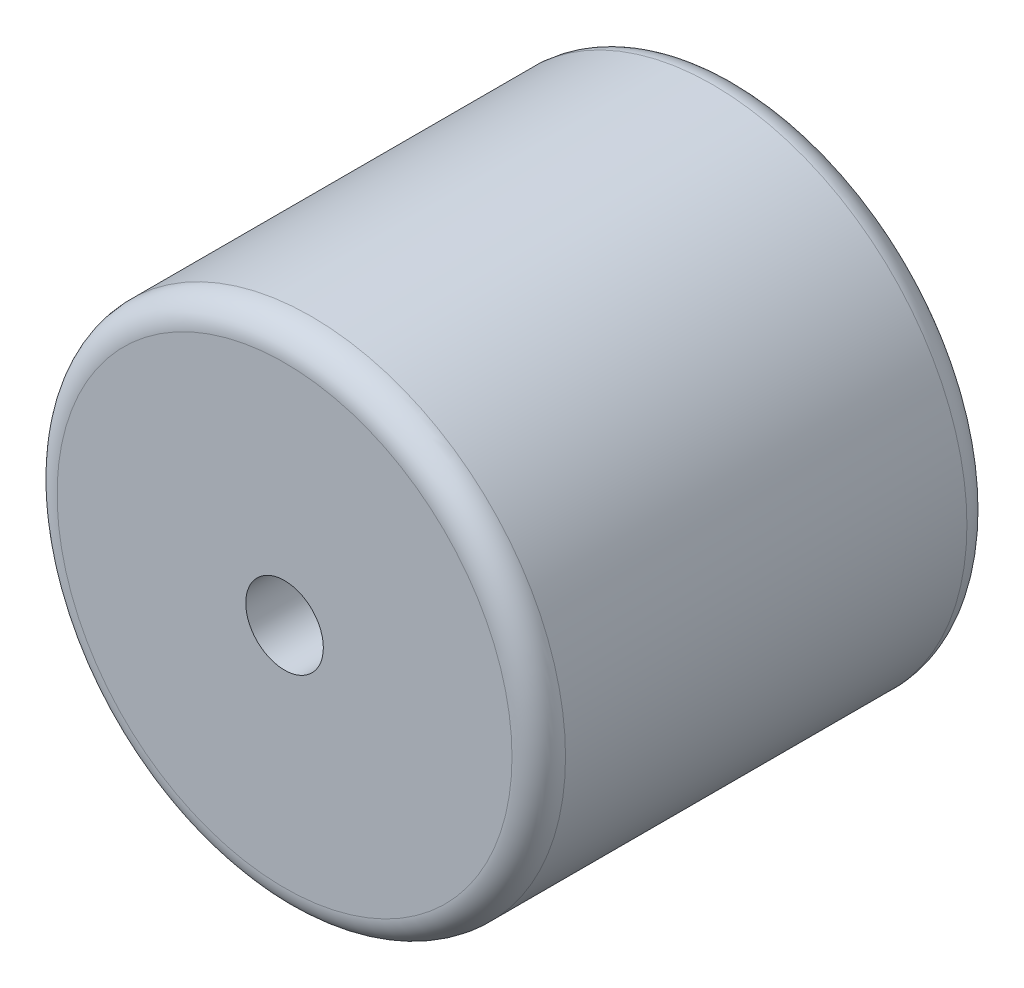
from build123d import *

# Parameters (mm, degrees)
SKETCH1_R           = 9.5
BOSS_EXTRUDE1_DEPTH = 17
FILLET1_R           = 1
SKETCH2_R           = 1.45
CUT_EXTRUDE1_DEPTH  = 17


with BuildPart() as part:
    # Sketch1 → Boss-Extrude1 (new body)
    with BuildSketch(Plane.XY):
        Circle(SKETCH1_R)
    extrude(amount=BOSS_EXTRUDE1_DEPTH)

    # Fillet1
    fillet1_edges = [part.edges().sort_by_distance(p)[0] for p in [
        (-9.5, 0, 0),
        (-9.5, 0, 17),
    ]]
    fillet(fillet1_edges, radius=FILLET1_R)

    # Sketch2 → Cut-Extrude1 (cut)
    with BuildSketch(Plane.XY.offset(17)):
        Circle(SKETCH2_R)
    extrude(amount=-CUT_EXTRUDE1_DEPTH, mode=Mode.SUBTRACT)


solid = part.part
